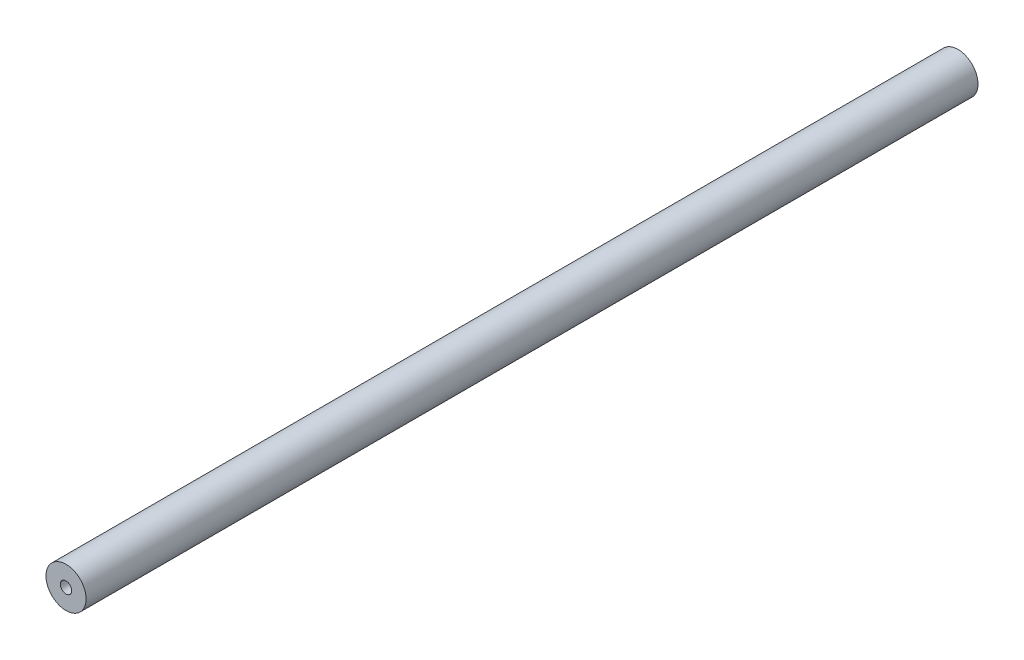
from build123d import *

# Parameters (mm, degrees)
SKETCH1_R           = 4
SKETCH1_R_2         = 1.1303
BOSS_EXTRUDE1_DEPTH = 177.8


with BuildPart() as part:
    # Sketch1 → Boss-Extrude1 (new body)
    with BuildSketch(Plane.XY):
        Circle(SKETCH1_R)
        Circle(SKETCH1_R_2, mode=Mode.SUBTRACT)
    extrude(amount=BOSS_EXTRUDE1_DEPTH)


solid = part.part
